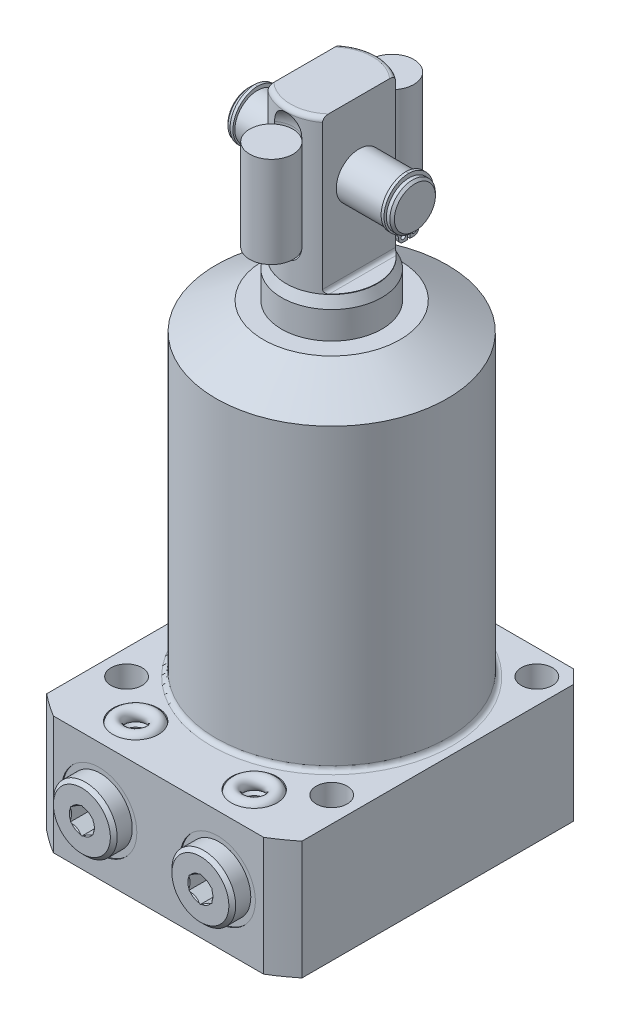
from build123d import *

# Parameters (mm, degrees)
FLATS_DEPTH            = 50
SKETCH23_R             = 0.52
RETAINING_RING_DEPTH   = 0.635
SKETCH24_W             = 4.7625
SKETCH24_H             = 20
SKETCH7_OUTSIDE_W      = 128.422
SKETCH7_OUTSIDE_H      = 128.422
SKETCH7_OUTSIDE_W_2    = 56
SKETCH7_OUTSIDE_H_2    = 66
FLANGE_SIDES_DEPTH     = 27
SKETCH8_R              = 3.4
MOUNTING_HOLES_DEPTH   = 140.2500001
MOUNTING_PATTERN_COUNT = 4
FLANGE_CHAMFER_SIZE    = 3
BODY_FILLET_R          = 1
BSPP_PLUG_HEX_DEPTH    = 4.06
SKETCH16_R             = 1.5


with BuildPart() as part:
    # Sketch1 → PLUNGER (revolve)
    with BuildSketch(Plane.XY, mode=Mode.PRIVATE) as plunger_sk:
        with BuildLine():
            Line((11, 0), (11, 77.5))
            Line((11, 77.5), (10, 79.644506921))
            Line((10, 79.644506921), (10, 112.25))
            ThreePointArc((10, 112.25), (9.707106781, 112.957106781), (9, 113.25))
            Line((9, 113.25), (0, 113.25))
            Line((0, 113.25), (0, 0))
            Line((0, 0), (11, 0))
        make_face()
    revolve(plunger_sk.sketch.rotate(Axis((0, -3.075, 0), (0, 1, 0)), 90), axis=Axis((0, -3.075, 0), (0, 1, 0)))  # turned: the seam where the file's is

    # Sketch17 → FLATS (cut, symmetric)
    with BuildSketch(Plane.XY):
        with BuildLine():
            Line((6, 113.25), (10, 113.25))
            Line((10, 113.25), (10, 79.75))
            Line((10, 79.75), (6.8, 79.75))
            ThreePointArc((6.8, 79.75), (6.234314575, 79.984314575), (6, 80.55))
            Line((6, 80.55), (6, 113.25))
        make_face()
        with BuildLine():
            Line((-10, 113.25), (-10, 79.75))
            Line((-10, 79.75), (-6.8, 79.75))
            ThreePointArc((-6.8, 79.75), (-6.234314575, 79.984314575), (-6, 80.55))
            Line((-6, 80.55), (-6, 113.25))
            Line((-6, 113.25), (-10, 113.25))
        make_face()
    extrude(amount=FLATS_DEPTH, both=True, mode=Mode.SUBTRACT)

    # Sketch22 → PIVOT_PIN (revolve)
    with BuildSketch(Plane.XY, mode=Mode.PRIVATE) as pivot_pin_sk:
        Polygon((-18.25, 102.75), (-17.75, 103.25), (-16.99, 103.25), (-16.99, 102.9365), (-16.25, 102.9365), (-16.25, 103.25), (16.25, 103.25), (16.25, 102.9365), (16.99, 102.9365), (16.99, 103.25), (17.75, 103.25), (18.25, 102.75), (18.25, 98.25), (-18.25, 98.25), align=None)
    revolve(pivot_pin_sk.sketch.rotate(Axis((-11.568872367, 98.25, 0), (1, 0, 0)), 90), axis=Axis((-11.568872367, 98.25, 0), (1, 0, 0)))  # turned: the seam where the file's is

    # Sketch23 → RETAINING_RING (add)
    with BuildSketch(Plane(origin=(16.25, 0, 0), x_dir=(0, 0, -1), z_dir=(1, 0, 0))):
        with BuildLine():
            Line((-0.2765, 91.553512203), (-1.17, 91.553512203))
            ThreePointArc((-1.17, 91.553512203), (-1.905391052, 91.858121151), (-2.21, 92.593512203))
            ThreePointArc((-2.21, 92.593512203), (-2.388394859, 93.29719698), (-2.880487216, 93.830902989))
            ThreePointArc((-2.880487216, 93.830902989), (-5.200628251, 100.006348721), (0, 104.065))
            ThreePointArc((0, 104.065), (5.200628251, 100.006348721), (2.880487216, 93.830902989))
            ThreePointArc((2.880487216, 93.830902989), (2.388394859, 93.29719698), (2.21, 92.593512203))
            ThreePointArc((2.21, 92.593512203), (1.905391052, 91.858121151), (1.17, 91.553512203))
            Line((1.17, 91.553512203), (0.2765, 91.553512203))
            Line((0.2765, 91.553512203), (0.2765, 93.763512203))
            ThreePointArc((0.2765, 93.763512203), (0, 102.745), (-0.2765, 93.763512203))
            Line((-0.2765, 93.763512203), (-0.2765, 91.553512203))
        make_face()
        with Locations((-1.17, 92.593512203)):
            Circle(SKETCH23_R, mode=Mode.SUBTRACT)
        with Locations(Location((1.17, 92.593512203, 0), (0, 0, 180))):  # turned: the seam where the file's is
            Circle(SKETCH23_R, mode=Mode.SUBTRACT)
    retaining_ring = extrude(amount=RETAINING_RING_DEPTH)

    # RETAINING_RING-OPP: RETAINING_RING across plane
    add(retaining_ring.mirror(Plane.ZY))

    # Sketch20 → SPRING_SLOT (revolve, cut)
    with BuildSketch(Plane.ZY):
        with BuildLine():
            Line((8.5, 108.75), (8.5, 87.75))
            ThreePointArc((8.5, 87.75), (9.894903955, 84.382403955), (13.2625, 82.9875))
            Line((13.2625, 82.9875), (13.2625, 113.5125))
            ThreePointArc((13.2625, 113.5125), (9.894903955, 112.117596045), (8.5, 108.75))
        make_face()
    spring_slot = revolve(axis=Axis((0, 85.047956129, 13.2625), (0, -1, 0)), mode=Mode.SUBTRACT)

    # SPRING_SLOT_OPP: SPRING_SLOT across plane
    add(spring_slot.mirror(Plane.XY), mode=Mode.SUBTRACT)

    # Sketch24 → SPRING (revolve)
    with BuildSketch(Plane.ZY):
        with Locations((-10.85125, 98.25)):
            Rectangle(SKETCH24_W, SKETCH24_H)
    spring = revolve(axis=Axis((0, 84.567834264, -13.2325), (0, -1, 0)))

    # SPRING_OPP: SPRING across plane
    add(spring.mirror(Plane.XY))

    # Sketch6 → BODY_REVOLVE (revolve)
    with BuildSketch(Plane.XY, mode=Mode.PRIVATE) as body_revolve_sk:
        Polygon((0, 71.5), (15, 71.5), (25.385, 65.504217454), (25.385, 0), (44.45, 0), (44.45, -26), (0, -26), align=None)
    revolve(body_revolve_sk.sketch.rotate(Axis((0, -26, 0), (0, 1, 0)), 90), axis=Axis((0, -26, 0), (0, 1, 0)))  # turned: the seam where the file's is

    # Sketch7 outside → FLANGE_SIDES (cut, through all)
    with BuildSketch(Plane(origin=(0, 0, 0), x_dir=(-1, 0, 0), z_dir=(0, 1, 0))):
        Rectangle(SKETCH7_OUTSIDE_W, SKETCH7_OUTSIDE_H)
        with Locations((0, 5)):
            Rectangle(SKETCH7_OUTSIDE_W_2, SKETCH7_OUTSIDE_H_2, mode=Mode.SUBTRACT)
    extrude(amount=-FLANGE_SIDES_DEPTH, mode=Mode.SUBTRACT)

    # Sketch8 → MOUNTING HOLES (cut, through all)
    with BuildSketch(Plane.XZ.offset(26)):
        with Locations(Location((-22.5, 22.5, 0), (0, 0, 270))):  # turned: the seam where the file's is
            Circle(SKETCH8_R)
    mounting_holes = extrude(amount=-MOUNTING_HOLES_DEPTH, mode=Mode.SUBTRACT)

    # MOUNTING_PATTERN: MOUNTING HOLES ×4 about axis
    mounting_pattern_axis = Axis((0, 0, 0), (0, 1, 0))
    for i in range(1, MOUNTING_PATTERN_COUNT):
        add(mounting_holes.rotate(mounting_pattern_axis, i * 360 / MOUNTING_PATTERN_COUNT), mode=Mode.SUBTRACT)

    # FLANGE_CHAMFER
    flange_chamfer_edges = [part.edges().sort_by_distance(p)[0] for p in [
        (-28, -13, -28),
        (28, -13, -28),
    ]]
    chamfer(flange_chamfer_edges, length=FLANGE_CHAMFER_SIZE)

    # BODY_FILLET
    body_fillet_edges = [part.edges().sort_by_distance(p)[0] for p in [
        (0, 0, 25.385),
    ]]
    fillet(body_fillet_edges, radius=BODY_FILLET_R)

    # Sketch11 → PORT SPOT FACE (revolve, cut)
    with BuildSketch(Plane.XZ.offset(13), mode=Mode.PRIVATE) as port_spot_face_sk:
        Polygon((-21.25, 38), (-21.25, 37.75), (-18, 37.75), (-17.42, 37.17), (-17.42, 22.59), (-13, 22.59), (-13, 38), align=None)
    port_spot_face = revolve(port_spot_face_sk.sketch.rotate(Axis((-13, -13, 42.971570338), (0, 0, -1)), 180), axis=Axis((-13, -13, 42.971570338), (0, 0, -1)), mode=Mode.SUBTRACT)  # turned: the seam where the file's is

    # Sketch13 → BOTTOM_MANIFOLD_PORT (revolve, cut)
    with BuildSketch(Plane.XY.offset(30)):
        Polygon((-15.5, -14), (-15.5, -23.125), (-16.125, -23.75), (-18, -23.75), (-18, -26), (-13, -26), (-13, -14), align=None)
    bottom_manifold_port = revolve(axis=Axis((-13, 15.209907045, 30), (0, -1, 0)), mode=Mode.SUBTRACT)

    # Sketch14 → BSPP_PLUGHEAD (revolve)
    with BuildSketch(Plane.XZ.offset(13)):
        Polygon((-15.75, 41.81), (-19.25, 41.81), (-20, 41.06), (-20, 37.75), (-17.125, 37.75), (-17.125, 35.30784845), (-13, 35.30784845), (-13, 35.30884845), (-15.5, 36.810999998), (-15.5, 41.56), align=None)
    bspp_plughead = revolve(axis=Axis((-13, -13, 32.588064048), (0, 0, 1)))

    # Sketch15 → BSPP_PLUG_HEX (cut)
    with BuildSketch(Plane.XY.offset(41.81)):
        Polygon((-10.5, -14.443375673), (-10.5, -11.556624327), (-13, -10.113248654), (-15.5, -11.556624327), (-15.5, -14.443375673), (-13, -15.886751346), align=None)
    bspp_plug_hex = extrude(amount=-BSPP_PLUG_HEX_DEPTH, mode=Mode.SUBTRACT)

    # MANIFOLD_TOP_MIRROR: BOTTOM_MANIFOLD_PORT across plane
    add(bottom_manifold_port.mirror(Plane(origin=(0, -13, 0), x_dir=(0, 0, 1), z_dir=(0, -1, 0))), mode=Mode.SUBTRACT)

    # BSPP-MANIFOLD_MIRROR: PORT SPOT FACE, BOTTOM_MANIFOLD_PORT, BSPP_PLUGHEAD, BSPP_PLUG_HEX across plane
    add(port_spot_face.mirror(Plane(origin=(0, 0, 0), x_dir=(0, 0, 1), z_dir=(1, 0, 0))), mode=Mode.SUBTRACT)
    add(bottom_manifold_port.mirror(Plane(origin=(0, 0, 0), x_dir=(0, 0, 1), z_dir=(1, 0, 0))), mode=Mode.SUBTRACT)
    add(bspp_plughead.mirror(Plane(origin=(0, 0, 0), x_dir=(0, 0, 1), z_dir=(1, 0, 0))))
    add(bspp_plug_hex.mirror(Plane(origin=(0, 0, 0), x_dir=(0, 0, 1), z_dir=(1, 0, 0))), mode=Mode.SUBTRACT)

    # BSPP-MANIFOLD_MIRROR copy 1 sketch → BSPP-MANIFOLD_MIRROR copy 1 (revolve, cut)
    with BuildSketch(Plane(origin=(0, -26, 30), x_dir=(-1, 0, 0), z_dir=(0, 0, 1))):
        Polygon((-15.5, -14), (-15.5, -23.125), (-16.125, -23.75), (-18, -23.75), (-18, -26), (-13, -26), (-13, -14), align=None)
    revolve(axis=Axis((13, -41.209907045, 30), (0, 1, 0)), mode=Mode.SUBTRACT)


with BuildPart() as body_2:
    # Sketch16 → MANIFOLD_O-RING (revolve)
    with BuildSketch(Plane.XY.offset(30)):
        with Locations((-16.5, -25.25)):
            Circle(SKETCH16_R)
    revolve(axis=Axis((-13, 9.321927472, 30), (0, -1, 0)))


with BuildPart() as body_3:
    # MANIFOLD_O-RING_MIRROR: mirrored copy
    add(body_2.part.mirror(Plane(origin=(0, 0, 0), x_dir=(0, 0, 1), z_dir=(1, 0, 0))))


with BuildPart() as body_4:
    # MANIFOLD_O-RING_MIRROR_TOP: mirrored copy
    add(body_2.part.mirror(Plane(origin=(0, -13, 0), x_dir=(0, 0, 1), z_dir=(0, -1, 0))))


with BuildPart() as body_5:
    # MANIFOLD_O-RING_MIRROR_TOP 2: mirrored copy
    add(body_3.part.mirror(Plane(origin=(0, -13, 0), x_dir=(0, 0, 1), z_dir=(0, -1, 0))))


solid = Compound([part.part, body_2.part, body_3.part, body_4.part, body_5.part])
